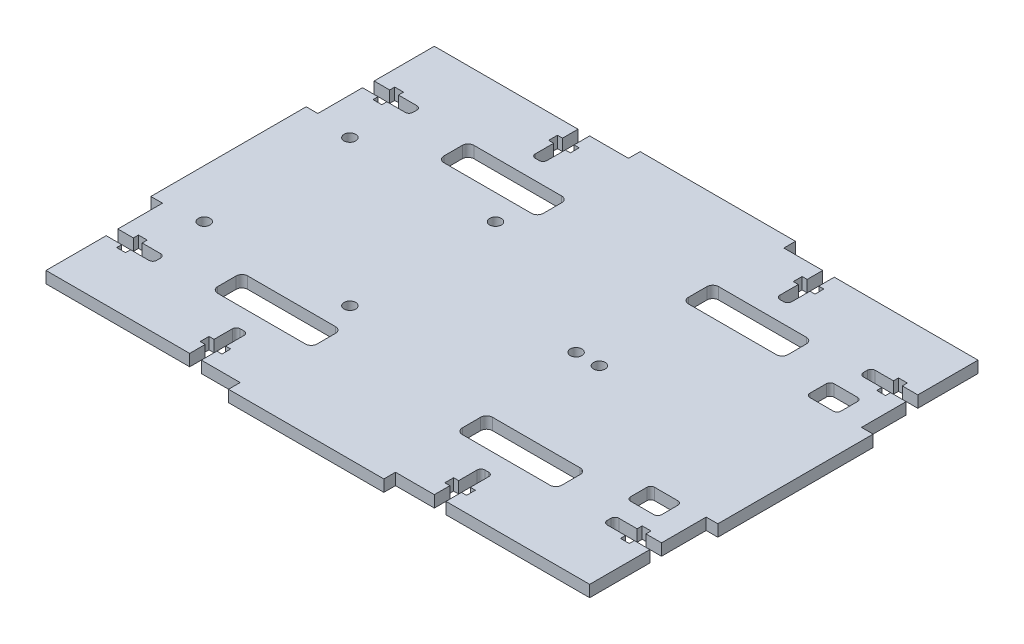
from build123d import *

# Parameters (mm, degrees)
ESBO_O1_W                  = 140
ESBO_O1_H                  = 100
RESSALTO_EXTRUS_O1_DEPTH   = 1.5
ESBO_O4_W                  = 3
ESBO_O4_H                  = 40
ESBO_O4_W_2                = 40
ESBO_O4_H_2                = 3
RESSALTO_EXTRUS_O2_DEPTH   = 3
CORTE_EXTRUS_O1_DEPTH      = 4
CORTE_EXTRUS_O4_DEPTH      = 4
ESBO_O13_R                 = 1.5
CORTE_EXTRUS_O8_DEPTH      = 1
CORTE_EXTRUS_O8_DEPTH_BACK = 4
SKETCH3_R                  = 1.5
CUT_EXTRUDE2_DEPTH         = 1
CUT_EXTRUDE2_DEPTH_BACK    = 4
CUT_EXTRUDE3_DEPTH         = 2.5
CUT_EXTRUDE3_DEPTH_BACK    = 2.5


with BuildPart() as part:
    # Esboço1 → Ressalto-extrusão1 (new body, symmetric)
    with BuildSketch(Plane(origin=(0, 0, 0), x_dir=(1, 0, 0), z_dir=(0, 1, 0))):
        Rectangle(ESBO_O1_W, ESBO_O1_H)
    extrude(amount=RESSALTO_EXTRUS_O1_DEPTH, both=True)

    # Esboço4 → Ressalto-extrusão2 (add, through all)
    with BuildSketch(Plane(origin=(0, 1.5, 0), x_dir=(1, 0, 0), z_dir=(0, 1, 0))):
        with Locations((-71.5, 0)):
            Rectangle(ESBO_O4_W, ESBO_O4_H)
        with Locations((0, 51.5)):
            Rectangle(ESBO_O4_W_2, ESBO_O4_H_2)
        with Locations((0, -51.5)):
            Rectangle(ESBO_O4_W_2, ESBO_O4_H_2)
        with Locations((71.5, 0)):
            Rectangle(ESBO_O4_W, ESBO_O4_H)
    extrude(amount=-RESSALTO_EXTRUS_O2_DEPTH)

    # Esboço2 → Corte-extrusão1 (cut, through all)
    with BuildSketch(Plane(origin=(0, 1.5, 0), x_dir=(1, 0, 0), z_dir=(0, 1, 0))):
        with BuildLine():
            Line((-33, -43.73), (-33, -39))
            ThreePointArc((-33, -39), (-32.707106781, -38.292893219), (-32, -38))
            Line((-32, -38), (-31, -38))
            ThreePointArc((-31, -38), (-30.292893219, -38.292893219), (-30, -39))
            Line((-30, -39), (-30, -43.73))
            Line((-30, -43.73), (-28.7, -43.73))
            Line((-28.7, -43.73), (-28.7, -46))
            Line((-28.7, -46), (-30, -46))
            Line((-30, -46), (-30, -50))
            Line((-30, -50), (-33, -50))
            Line((-33, -50), (-33, -46))
            Line((-33, -46), (-34.3, -46))
            Line((-34.3, -46), (-34.3, -43.73))
            Line((-34.3, -43.73), (-33, -43.73))
        make_face()
        with BuildLine():
            Line((-28.7, 46), (-28.7, 43.73))
            Line((-28.7, 43.73), (-30, 43.73))
            Line((-30, 43.73), (-30, 39))
            ThreePointArc((-30, 39), (-30.292893219, 38.292893219), (-31, 38))
            Line((-31, 38), (-32, 38))
            ThreePointArc((-32, 38), (-32.707106781, 38.292893219), (-33, 39))
            Line((-33, 39), (-33, 43.73))
            Line((-33, 43.73), (-34.3, 43.73))
            Line((-34.3, 43.73), (-34.3, 46))
            Line((-34.3, 46), (-33, 46))
            Line((-33, 46), (-33, 50))
            Line((-33, 50), (-30, 50))
            Line((-30, 50), (-30, 46))
            Line((-30, 46), (-28.7, 46))
        make_face()
        with BuildLine():
            Line((33, 43.73), (33, 39))
            ThreePointArc((33, 39), (32.707106781, 38.292893219), (32, 38))
            Line((32, 38), (31, 38))
            ThreePointArc((31, 38), (30.292893219, 38.292893219), (30, 39))
            Line((30, 39), (30, 43.73))
            Line((30, 43.73), (28.7, 43.73))
            Line((28.7, 43.73), (28.7, 46))
            Line((28.7, 46), (30, 46))
            Line((30, 46), (30, 50))
            Line((30, 50), (33, 50))
            Line((33, 50), (33, 46))
            Line((33, 46), (34.3, 46))
            Line((34.3, 46), (34.3, 43.73))
            Line((34.3, 43.73), (33, 43.73))
        make_face()
        with BuildLine():
            Line((28.7, -46), (28.7, -43.73))
            Line((28.7, -43.73), (30, -43.73))
            Line((30, -43.73), (30, -39))
            ThreePointArc((30, -39), (30.292893219, -38.292893219), (31, -38))
            Line((31, -38), (32, -38))
            ThreePointArc((32, -38), (32.707106781, -38.292893219), (33, -39))
            Line((33, -39), (33, -43.73))
            Line((33, -43.73), (34.3, -43.73))
            Line((34.3, -43.73), (34.3, -46))
            Line((34.3, -46), (33, -46))
            Line((33, -46), (33, -50))
            Line((33, -50), (30, -50))
            Line((30, -50), (30, -46))
            Line((30, -46), (28.7, -46))
        make_face()
    extrude(amount=-CORTE_EXTRUS_O1_DEPTH, mode=Mode.SUBTRACT)

    # Esboço7 → Corte-extrusão4 (cut, through all)
    with BuildSketch(Plane(origin=(0, 1.5, 0), x_dir=(1, 0, 0), z_dir=(0, 1, 0))):
        with BuildLine():
            Line((-70, -31.5), (-66, -31.5))
            Line((-66, -31.5), (-66, -30.2))
            Line((-66, -30.2), (-63.73, -30.2))
            Line((-63.73, -30.2), (-63.73, -31.5))
            Line((-63.73, -31.5), (-59, -31.5))
            ThreePointArc((-59, -31.5), (-58.292893219, -31.792893219), (-58, -32.5))
            Line((-58, -32.5), (-58, -33.5))
            ThreePointArc((-58, -33.5), (-58.292893219, -34.207106781), (-59, -34.5))
            Line((-59, -34.5), (-63.73, -34.5))
            Line((-63.73, -34.5), (-63.73, -35.8))
            Line((-63.73, -35.8), (-66, -35.8))
            Line((-66, -35.8), (-66, -34.5))
            Line((-66, -34.5), (-70, -34.5))
            Line((-70, -34.5), (-70, -31.5))
        make_face()
        with BuildLine():
            Line((66, -34.5), (66, -35.8))
            Line((66, -35.8), (63.73, -35.8))
            Line((63.73, -35.8), (63.73, -34.5))
            Line((63.73, -34.5), (59, -34.5))
            ThreePointArc((59, -34.5), (58.292893219, -34.207106781), (58, -33.5))
            Line((58, -33.5), (58, -32.5))
            ThreePointArc((58, -32.5), (58.292893219, -31.792893219), (59, -31.5))
            Line((59, -31.5), (63.73, -31.5))
            Line((63.73, -31.5), (63.73, -30.2))
            Line((63.73, -30.2), (66, -30.2))
            Line((66, -30.2), (66, -31.5))
            Line((66, -31.5), (70, -31.5))
            Line((70, -31.5), (70, -34.5))
            Line((70, -34.5), (66, -34.5))
        make_face()
        with BuildLine():
            Line((70, 31.5), (66, 31.5))
            Line((66, 31.5), (66, 30.2))
            Line((66, 30.2), (63.73, 30.2))
            Line((63.73, 30.2), (63.73, 31.5))
            Line((63.73, 31.5), (59, 31.5))
            ThreePointArc((59, 31.5), (58.292893219, 31.792893219), (58, 32.5))
            Line((58, 32.5), (58, 33.5))
            ThreePointArc((58, 33.5), (58.292893219, 34.207106781), (59, 34.5))
            Line((59, 34.5), (63.73, 34.5))
            Line((63.73, 34.5), (63.73, 35.8))
            Line((63.73, 35.8), (66, 35.8))
            Line((66, 35.8), (66, 34.5))
            Line((66, 34.5), (70, 34.5))
            Line((70, 34.5), (70, 31.5))
        make_face()
        with BuildLine():
            Line((-66, 34.5), (-66, 35.8))
            Line((-66, 35.8), (-63.73, 35.8))
            Line((-63.73, 35.8), (-63.73, 34.5))
            Line((-63.73, 34.5), (-59, 34.5))
            ThreePointArc((-59, 34.5), (-58.292893219, 34.207106781), (-58, 33.5))
            Line((-58, 33.5), (-58, 32.5))
            ThreePointArc((-58, 32.5), (-58.292893219, 31.792893219), (-59, 31.5))
            Line((-59, 31.5), (-63.73, 31.5))
            Line((-63.73, 31.5), (-63.73, 30.2))
            Line((-63.73, 30.2), (-66, 30.2))
            Line((-66, 30.2), (-66, 31.5))
            Line((-66, 31.5), (-70, 31.5))
            Line((-70, 31.5), (-70, 34.5))
            Line((-70, 34.5), (-66, 34.5))
        make_face()
    extrude(amount=-CORTE_EXTRUS_O4_DEPTH, mode=Mode.SUBTRACT)

    # Esboço13 → Corte-extrusão8 (cut, two sides)
    with BuildSketch(Plane(origin=(0, -1.5, 0), x_dir=(-1, 0, 0), z_dir=(0, -1, 0))) as corte_extrus_o8_sk:
        with Locations((60.5, -18.75)):
            Circle(ESBO_O13_R)
        with Locations((23, -18.75)):
            Circle(ESBO_O13_R)
        with Locations((60.5, 18.75)):
            Circle(ESBO_O13_R)
        with Locations((23, 18.75)):
            Circle(ESBO_O13_R)
    extrude(amount=CORTE_EXTRUS_O8_DEPTH, mode=Mode.SUBTRACT)
    extrude(corte_extrus_o8_sk.sketch, amount=-CORTE_EXTRUS_O8_DEPTH_BACK, mode=Mode.SUBTRACT)

    # Sketch3 → Cut-Extrude2 (cut, two sides)
    with BuildSketch(Plane(origin=(0, 1.5, 0), x_dir=(1, 0, 0), z_dir=(0, 1, 0))) as cut_extrude2_sk:
        with Locations((16.5, 0)):
            Circle(SKETCH3_R)
        with Locations((22.5, 0)):
            Circle(SKETCH3_R)
    extrude(amount=CUT_EXTRUDE2_DEPTH, mode=Mode.SUBTRACT)
    extrude(cut_extrude2_sk.sketch, amount=-CUT_EXTRUDE2_DEPTH_BACK, mode=Mode.SUBTRACT)

    # Sketch4 → Cut-Extrude3 (cut, two sides)
    with BuildSketch(Plane(origin=(0, 0, 0), x_dir=(1, 0, 0), z_dir=(0, 1, 0))) as cut_extrude3_sk:
        with BuildLine():
            Line((-42.8, 33), (-20.2, 33))
            ThreePointArc((-20.2, 33), (-19.139339828, 32.560660172), (-18.7, 31.5))
            Line((-18.7, 31.5), (-18.7, 26.75))
            ThreePointArc((-18.7, 26.75), (-19.139339828, 25.689339828), (-20.2, 25.25))
            Line((-20.2, 25.25), (-42.8, 25.25))
            ThreePointArc((-42.8, 25.25), (-43.860660172, 25.689339828), (-44.3, 26.75))
            Line((-44.3, 26.75), (-44.3, 31.5))
            ThreePointArc((-44.3, 31.5), (-43.860660172, 32.560660172), (-42.8, 33))
        make_face()
        with BuildLine():
            Line((56.73, 26.2), (62.73, 26.2))
            ThreePointArc((62.73, 26.2), (63.437106781, 25.907106781), (63.73, 25.2))
            Line((63.73, 25.2), (63.73, 21))
            ThreePointArc((63.73, 21), (63.437106781, 20.292893219), (62.73, 20))
            Line((62.73, 20), (56.73, 20))
            ThreePointArc((56.73, 20), (56.022893219, 20.292893219), (55.73, 21))
            Line((55.73, 21), (55.73, 25.2))
            ThreePointArc((55.73, 25.2), (56.022893219, 25.907106781), (56.73, 26.2))
        make_face()
        with BuildLine():
            Line((63.73, -25.2), (63.73, -21))
            ThreePointArc((63.73, -21), (63.437106781, -20.292893219), (62.73, -20))
            Line((62.73, -20), (56.73, -20))
            ThreePointArc((56.73, -20), (56.022893219, -20.292893219), (55.73, -21))
            Line((55.73, -21), (55.73, -25.2))
            ThreePointArc((55.73, -25.2), (56.022893219, -25.907106781), (56.73, -26.2))
            Line((56.73, -26.2), (62.73, -26.2))
            ThreePointArc((62.73, -26.2), (63.437106781, -25.907106781), (63.73, -25.2))
        make_face()
        with BuildLine():
            Line((18.7, 31.5), (18.7, 26.75))
            ThreePointArc((18.7, 26.75), (19.139339828, 25.689339828), (20.2, 25.25))
            Line((20.2, 25.25), (42.8, 25.25))
            ThreePointArc((42.8, 25.25), (43.860660172, 25.689339828), (44.3, 26.75))
            Line((44.3, 26.75), (44.3, 31.5))
            ThreePointArc((44.3, 31.5), (43.860660172, 32.560660172), (42.8, 33))
            Line((42.8, 33), (20.2, 33))
            ThreePointArc((20.2, 33), (19.139339828, 32.560660172), (18.7, 31.5))
        make_face()
        with BuildLine():
            Line((42.8, -33), (20.2, -33))
            ThreePointArc((20.2, -33), (19.139339828, -32.560660172), (18.7, -31.5))
            Line((18.7, -31.5), (18.7, -26.75))
            ThreePointArc((18.7, -26.75), (19.139339828, -25.689339828), (20.2, -25.25))
            Line((20.2, -25.25), (42.8, -25.25))
            ThreePointArc((42.8, -25.25), (43.860660172, -25.689339828), (44.3, -26.75))
            Line((44.3, -26.75), (44.3, -31.5))
            ThreePointArc((44.3, -31.5), (43.860660172, -32.560660172), (42.8, -33))
        make_face()
        with BuildLine():
            Line((-18.7, -31.5), (-18.7, -26.75))
            ThreePointArc((-18.7, -26.75), (-19.139339828, -25.689339828), (-20.2, -25.25))
            Line((-20.2, -25.25), (-42.8, -25.25))
            ThreePointArc((-42.8, -25.25), (-43.860660172, -25.689339828), (-44.3, -26.75))
            Line((-44.3, -26.75), (-44.3, -31.5))
            ThreePointArc((-44.3, -31.5), (-43.860660172, -32.560660172), (-42.8, -33))
            Line((-42.8, -33), (-20.2, -33))
            ThreePointArc((-20.2, -33), (-19.139339828, -32.560660172), (-18.7, -31.5))
        make_face()
    extrude(amount=CUT_EXTRUDE3_DEPTH, mode=Mode.SUBTRACT)
    extrude(cut_extrude3_sk.sketch, amount=-CUT_EXTRUDE3_DEPTH_BACK, mode=Mode.SUBTRACT)


solid = part.part
